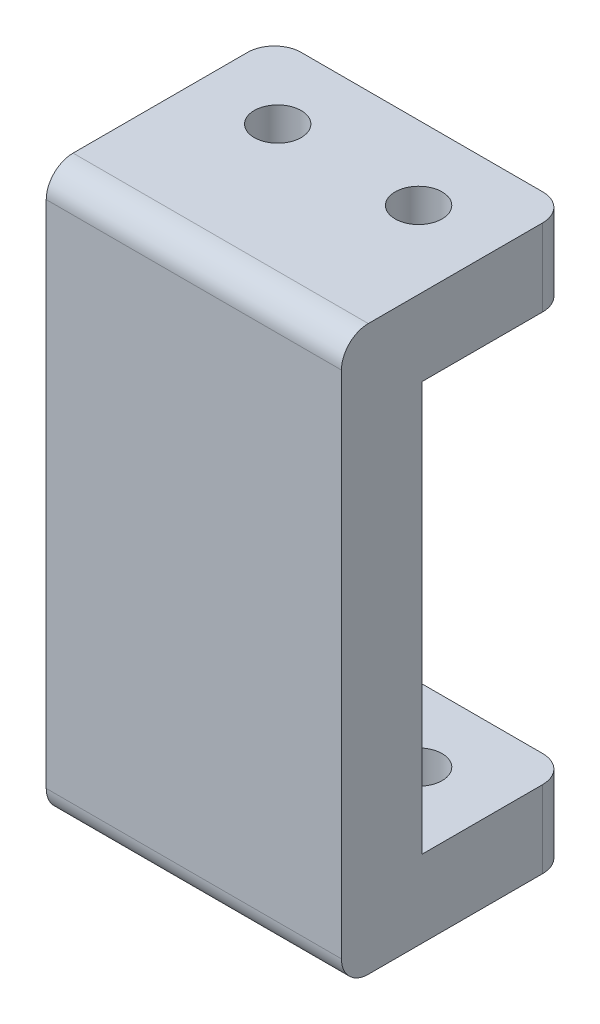
from build123d import *

# Parameters (mm, degrees)
SKETCH1_W           = 22
SKETCH1_H           = 6
SKETCH1_H_2         = 11
SKETCH1_R           = 1.75
BOSS_EXTRUDE1_DEPTH = 42
SKETCH2_W           = 22
SKETCH2_H           = 30.5
CUT_EXTRUDE1_DEPTH  = 11
FILLET1_R           = 2


with BuildPart() as part:
    # Sketch1 → Boss-Extrude1 (new body)
    with BuildSketch(Plane(origin=(0, 0, 0), x_dir=(1, 0, 0), z_dir=(0, 1, 0))):
        with Locations((0, -8.5)):
            Rectangle(SKETCH1_W, SKETCH1_H)
        Rectangle(SKETCH1_W, SKETCH1_H_2)
        with Locations((5.25, 0)):
            Circle(SKETCH1_R, mode=Mode.SUBTRACT)
        with Locations((-5.25, 0)):
            Circle(SKETCH1_R, mode=Mode.SUBTRACT)
    extrude(amount=BOSS_EXTRUDE1_DEPTH)

    # Sketch2 → Cut-Extrude1 (cut)
    with BuildSketch(Plane(origin=(0, 0, -5.5), x_dir=(-1, 0, 0), z_dir=(0, 0, -1))):
        with Locations((0, 21)):
            Rectangle(SKETCH2_W, SKETCH2_H)
    extrude(amount=-CUT_EXTRUDE1_DEPTH, mode=Mode.SUBTRACT)

    # Fillet1
    fillet1_edges = [part.edges().sort_by_distance(p)[0] for p in [
        (0, 0, 11.5),
        (-11, 39.125, -5.5),
        (11, 39.125, -5.5),
        (-11, 2.875, -5.5),
        (11, 2.875, -5.5),
        (0, 42, 11.5),
    ]]
    fillet(fillet1_edges, radius=FILLET1_R)


solid = part.part
